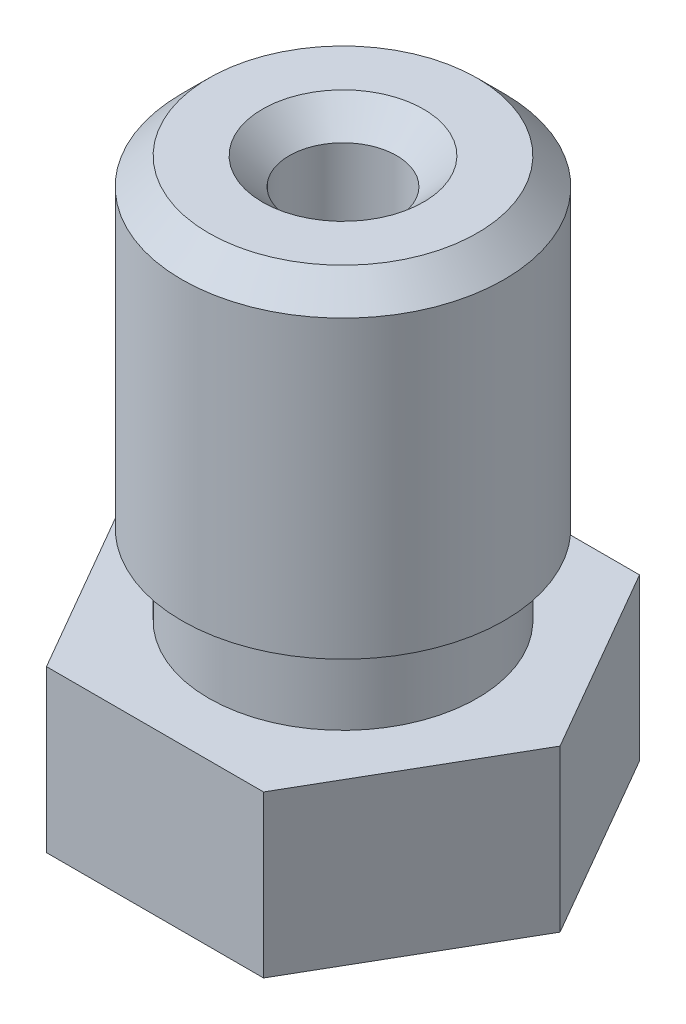
from build123d import *

# Parameters (mm, degrees)
BOSS_EXTRUDE1_DEPTH = 3
CHAMFER1_SIZE       = 0.5


with BuildPart() as part:
    # Sketch1 → Boss-Extrude1 (new body)
    with BuildSketch(Plane.XZ):
        Polygon((-2.020725942, 3.5), (-4.041451884, 0), (-2.020725942, -3.5), (2.020725942, -3.5), (4.041451884, 0), (2.020725942, 3.5), align=None)
    extrude(amount=-BOSS_EXTRUDE1_DEPTH)

    # Sketch2 → Revolve1 (revolve)
    with BuildSketch(Plane(origin=(0, 0, 0), x_dir=(-1, 0, 0), z_dir=(0, 0, -1))):
        Polygon((-2.5, 3), (0, 3), (0, 10.5), (-3, 10.5), (-3, 4.5), (-2.5, 4.5), align=None)
    revolve(axis=Axis((0, 3, 0), (0, 1, 0)))

    # Sketch3 → Revolve2 (revolve)
    with BuildSketch(Plane.XY):
        Polygon((2.5, 0), (0, 0), (0, -2), (0.5, -2), align=None)
    revolve(axis=Axis((0, 0, 0), (0, -1, 0)))

    # Sketch4 → Cut-Revolve1 (revolve, cut)
    with BuildSketch(Plane(origin=(0, 0, 0), x_dir=(-1, 0, 0), z_dir=(0, 0, -1))):
        Polygon((-0.3, -2), (0, -2), (0, 10.5), (-1, 10.5), (-1, 0), (-0.75, -0.227272727), (-0.75, -0.7), (-0.3, -1.2), align=None)
    revolve(axis=Axis((0, -2, 0), (0, 1, 0)), mode=Mode.SUBTRACT)

    # Chamfer1
    chamfer1_edges = [part.edges().sort_by_distance(p)[0] for p in [
        (-3, 10.5, 0),
        (-1, 10.5, 0),
    ]]
    chamfer(chamfer1_edges, length=CHAMFER1_SIZE)


solid = part.part
